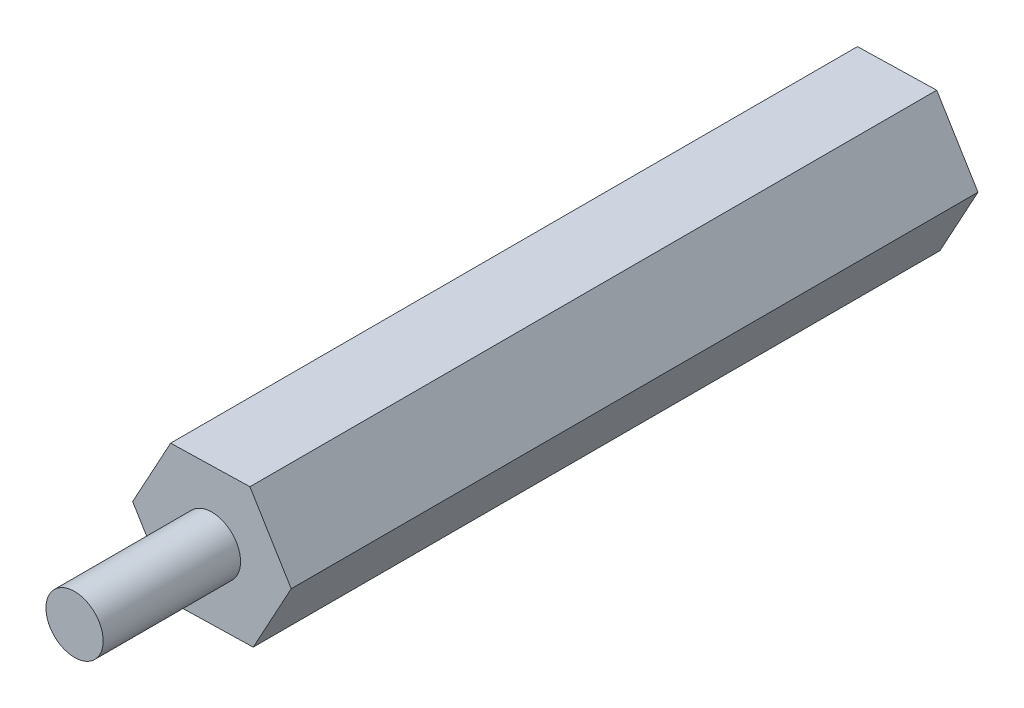
from build123d import *

# Parameters (mm, degrees)
EXTRUDE_1_DEPTH     = 30
SKETCH_2_R          = 1.25
EXTRUDE_2_DEPTH     = 6
SKETCH_3_R          = 1.25
CUT_EXTRUDE_1_DEPTH = 20


with BuildPart() as part:
    # 草图1 → 凸台-拉伸1 (new body)
    with BuildSketch(Plane.XY):
        Polygon((1.659979091, 3.040471907), (-1.803136365, 2.957820016), (-3.463115456, -0.082651891), (-1.659979091, -3.040471907), (1.803136365, -2.957820016), (3.463115456, 0.082651891), align=None)
    extrude(amount=EXTRUDE_1_DEPTH)

    # 草图2 → 凸台-拉伸2 (add)
    with BuildSketch(Plane.XY.offset(30)):
        Circle(SKETCH_2_R)
    extrude(amount=EXTRUDE_2_DEPTH)

    # 草图3 → 切除-拉伸1 (cut)
    with BuildSketch(Plane(origin=(0, 0, 0), x_dir=(-1, 0, 0), z_dir=(0, 0, -1))):
        Circle(SKETCH_3_R)
    extrude(amount=-CUT_EXTRUDE_1_DEPTH, mode=Mode.SUBTRACT)


solid = part.part
